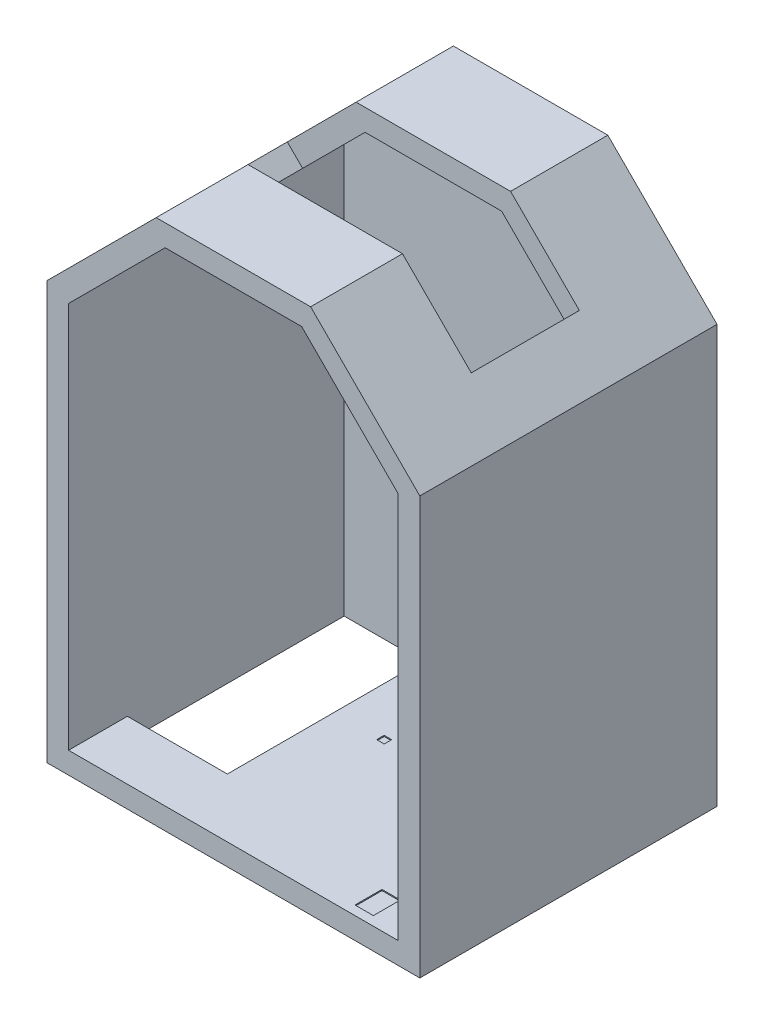
from build123d import *

# Parameters (mm, degrees)
BASE_DEPTH           = 2550
FLOOR_2_DEPTH        = 200
SKETCH13_W           = 1000
SKETCH13_H           = 900
WINDOW_RIGHT_DEPTH   = 5171.960671741
SKETCH14_W           = 1429.036790187
SKETCH14_H           = 1000
WINDOW_CENTER_DEPTH  = 500
SKETCH8_W            = 170
SKETCH8_H            = 250
VENTILATION_DEPTH    = 10
SKETCH9_R            = 15
SKETCH9_R_2          = 32.5
SKETCH9_W            = 70
SKETCH9_H            = 70
SOCKET_PIPES_DEPTH   = 10
SKETCH10_W           = 100
SKETCH10_H           = 100
SKETCH10_W_2         = 70
SKETCH10_H_2         = 140
SOCKET_DEPTH         = 5
SKETCH12_W           = 1072.28008248
SKETCH12_H           = 544.020295296
DOOR_HIGH_WALL_DEPTH = 200
WALL_DEPTH           = 2550
SKETCH15_W           = 1000
SKETCH15_H           = 900
WINDOW_LEFT_DEPTH    = 500


with BuildPart() as part:
    # Sketch1 → Base (new body)
    with BuildSketch(Plane.XY):
        Polygon((959.373842867, -990), (959.373842867, 2590), (66.049525486, 3483.324317381), (-1197.301839752, 3483.324317381), (-1280.144552227, 3683.324317381), (148.89223796, 3683.324317381), (1159.373842867, 2672.842712475), (1159.373842867, -1190), (-1165.626157133, -1190), (-1165.626157133, -990), align=None)
    extrude(amount=BASE_DEPTH)

    # Sketch5 → Floor 2 (add)
    with BuildSketch(Plane.XY):
        Polygon((1159.373842867, 2672.842712475), (1159.373842867, -1190), (-2290.626157133, -1190), (-2290.626157133, 2672.842712475), (-1280.144552227, 3683.324317381), (148.89223796, 3683.324317381), align=None)
    extrude(amount=-FLOOR_2_DEPTH)

    # Sketch13 → Window right (cut, through all)
    with BuildSketch(Plane(origin=(1916.108277671, 1916.108277671, 0), x_dir=(0, 0, -1), z_dir=(0.707106781, 0.707106781, 0))):
        with Locations((-1200, 2049.220891002)):
            Rectangle(SKETCH13_W, SKETCH13_H)
    extrude(amount=-WINDOW_RIGHT_DEPTH, mode=Mode.SUBTRACT)

    # Sketch14 → Window center (cut)
    with BuildSketch(Plane(origin=(0, 3683.324317381, 0), x_dir=(1, 0, 0), z_dir=(0, 1, 0))):
        with Locations((-565.626157133, -1200)):
            Rectangle(SKETCH14_W, SKETCH14_H)
    extrude(amount=-WINDOW_CENTER_DEPTH, mode=Mode.SUBTRACT)

    # Sketch8 → Ventilation (cut)
    with BuildSketch(Plane(origin=(0, -990, 0), x_dir=(1, 0, 0), z_dir=(0, 1, 0))):
        with Locations((559.373842867, -2340)):
            Rectangle(SKETCH8_W, SKETCH8_H)
    extrude(amount=-VENTILATION_DEPTH, mode=Mode.SUBTRACT)

    # Sketch9 → Socket & pipes (cut)
    with BuildSketch(Plane(origin=(0, -990, 0), x_dir=(1, 0, 0), z_dir=(0, 1, 0))):
        with Locations((439.373842867, -400)):
            Circle(SKETCH9_R)
        with Locations((439.373842867, -285)):
            Circle(SKETCH9_R)
        with Locations((244.373842867, -75)):
            Circle(SKETCH9_R_2)
        with Locations((-715.626157133, -1005)):
            Rectangle(SKETCH9_W, SKETCH9_H)
    extrude(amount=-SOCKET_PIPES_DEPTH, mode=Mode.SUBTRACT)

    # Sketch10 → Socket (cut)
    with BuildSketch(Plane.ZY.offset(-959.373842867)):
        with Locations((1145, 370)):
            Rectangle(SKETCH10_W, SKETCH10_H)
        with Locations((1145, 515)):
            Rectangle(SKETCH10_W_2, SKETCH10_H_2)
    extrude(amount=-SOCKET_DEPTH, mode=Mode.SUBTRACT)

    # Sketch12 → Door high wall (add)
    with BuildSketch(Plane.XZ.offset(1190)):
        with Locations((-1701.766198373, 2277.989852352)):
            Rectangle(SKETCH12_W, SKETCH12_H)
    extrude(amount=-DOOR_HIGH_WALL_DEPTH)

    # Sketch6 → Wall (add)
    with BuildSketch(Plane.XY):
        Polygon((-1280.144552227, 3683.324317381), (-1197.301839752, 3483.324317381), (-2090.626157133, 2590), (-2090.626157133, -1190), (-2290.626157133, -1190), (-2290.626157133, 2672.842712475), align=None)
    extrude(amount=WALL_DEPTH)

    # Sketch15 → Window left (cut)
    with BuildSketch(Plane(origin=(-2481.734434804, 2481.734434804, 0), x_dir=(0, 0, 1), z_dir=(-0.707106781, 0.707106781, 0))):
        with Locations((1200, 1249.304708351)):
            Rectangle(SKETCH15_W, SKETCH15_H)
    extrude(amount=-WINDOW_LEFT_DEPTH, mode=Mode.SUBTRACT)


solid = part.part
